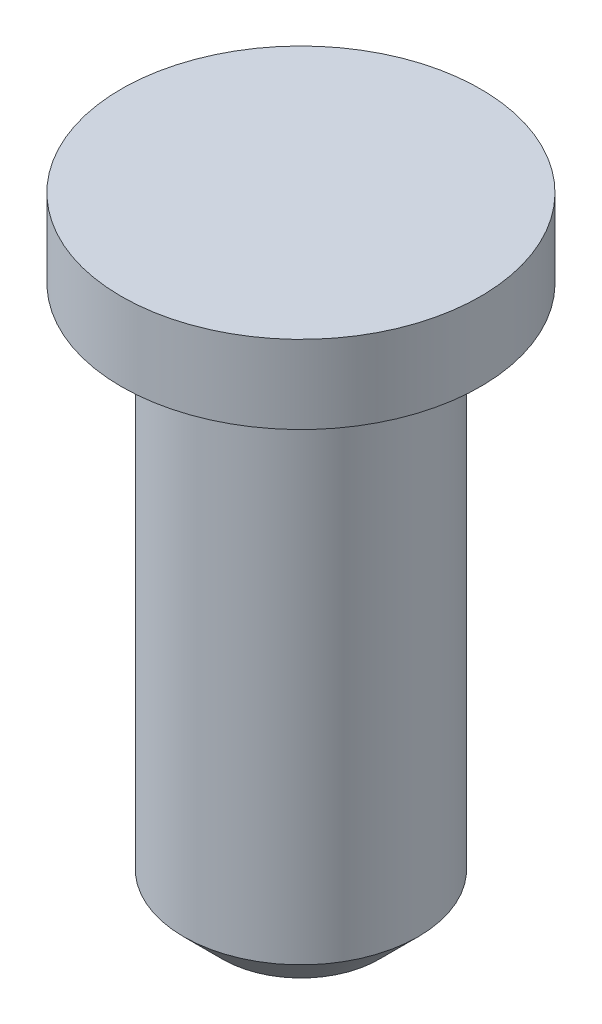
from build123d import *

# Parameters (mm, degrees)
CHAFL_N1_SIZE = 0.5


with BuildPart() as part:
    # Croquis1 → Revolución1 (revolve)
    with BuildSketch(Plane.XY):
        Polygon((0, 0), (2.3, 0), (2.3, -1), (1.5, -1), (1.5, -8), (0, -8), align=None)
    revolve(axis=Axis((0, 0, 0), (0, -1, 0)))

    # Chaflán1
    chafl_n1_edges = [part.edges().sort_by_distance(p)[0] for p in [
        (-1.5, -8, 0),
    ]]
    chamfer(chafl_n1_edges, length=CHAFL_N1_SIZE)


solid = part.part
